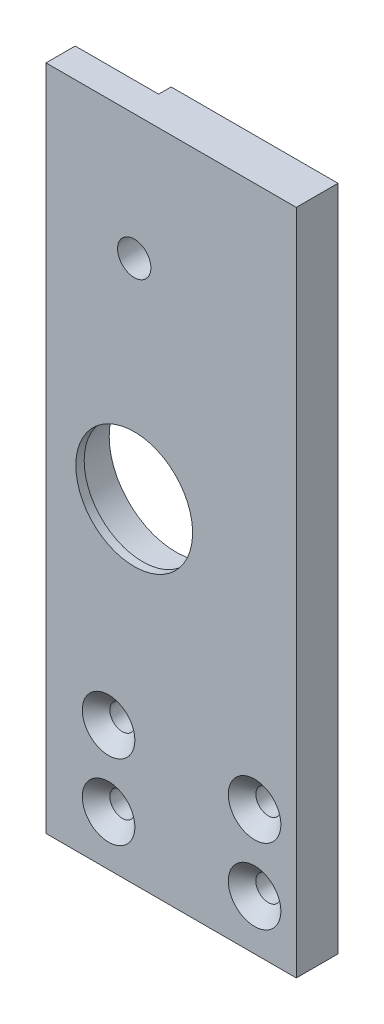
from build123d import *

# Parameters (mm, degrees)
SKIZZE1_W                        = 65
SKIZZE1_H                        = 160
AUFSATZ_LINEAR_AUSTRAGEN1_DEPTH  = 10
SKIZZE2_R                        = 16
SCHNITT_LINEAR_AUSTRAGEN1_DEPTH  = 8
SKIZZE3_W                        = 20
SKIZZE3_H                        = 3
SCHNITT_LINEAR_AUSTRAGEN2_DEPTH  = 15
SKIZZE4_R                        = 4
SCHNITT_LINEAR_AUSTRAGEN3_DEPTH  = 20
SKIZZE6_R                        = 14
SCHNITT_LINEAR_AUSTRAGEN4_DEPTH  = 20
SKIZZE7_R                        = 1.62
SCHNITT_LINEAR_AUSTRAGEN5_DEPTH  = 5
SKIZZE8_R                        = 1.62
SCHNITT_LINEAR_AUSTRAGEN6_DEPTH  = 5
SKIZZE9_R                        = 3
SCHNITT_LINEAR_AUSTRAGEN7_DEPTH  = 32
FASE1_SIZE                       = 3.3
SKIZZE10_R                       = 3
SCHNITT_LINEAR_AUSTRAGEN8_DEPTH  = 32
FASE2_SIZE                       = 3.3
SKIZZE11_R                       = 3
SCHNITT_LINEAR_AUSTRAGEN9_DEPTH  = 32
FASE3_SIZE                       = 3.3
SKIZZE12_R                       = 3
SCHNITT_LINEAR_AUSTRAGEN10_DEPTH = 25
FASE4_SIZE                       = 3.3
SKIZZE13_W                       = 10
SKIZZE13_H                       = 160
SCHNITT_LINEAR_AUSTRAGEN11_DEPTH = 5


with BuildPart() as part:
    # Skizze1 → Aufsatz-Linear austragen1 (new body)
    with BuildSketch(Plane.XY):
        with Locations((32.5, 80)):
            Rectangle(SKIZZE1_W, SKIZZE1_H)
    extrude(amount=AUFSATZ_LINEAR_AUSTRAGEN1_DEPTH)

    # Skizze2 → Schnitt-Linear austragen1 (cut)
    with BuildSketch(Plane(origin=(0, 0, 0), x_dir=(-1, 0, 0), z_dir=(0, 0, -1))):
        with Locations((-21.15, 80)):
            Circle(SKIZZE2_R)
    extrude(amount=-SCHNITT_LINEAR_AUSTRAGEN1_DEPTH, mode=Mode.SUBTRACT)

    # Skizze3 → Schnitt-Linear austragen2 (cut)
    with BuildSketch(Plane(origin=(0, 160, 0), x_dir=(1, 0, 0), z_dir=(0, 1, 0))):
        with Locations((10, -1.5)):
            Rectangle(SKIZZE3_W, SKIZZE3_H)
    extrude(amount=-SCHNITT_LINEAR_AUSTRAGEN2_DEPTH, mode=Mode.SUBTRACT)

    # Skizze4 → Schnitt-Linear austragen3 (cut)
    with BuildSketch(Plane(origin=(0, 0, 0), x_dir=(-1, 0, 0), z_dir=(0, 0, -1))):
        with Locations((-21.15, 130)):
            Circle(SKIZZE4_R)
    extrude(amount=-SCHNITT_LINEAR_AUSTRAGEN3_DEPTH, mode=Mode.SUBTRACT)

    # Skizze6 → Schnitt-Linear austragen4 (cut)
    with BuildSketch(Plane(origin=(0, 0, 8), x_dir=(-1, 0, 0), z_dir=(0, 0, -1))):
        with Locations((-21.15, 80)):
            Circle(SKIZZE6_R)
    extrude(amount=-SCHNITT_LINEAR_AUSTRAGEN4_DEPTH, mode=Mode.SUBTRACT)

    # Skizze7 → Schnitt-Linear austragen5 (cut)
    with BuildSketch(Plane(origin=(0, 0, 3), x_dir=(-1, 0, 0), z_dir=(0, 0, -1))):
        with Locations((-5, 151)):
            Circle(SKIZZE7_R)
    extrude(amount=-SCHNITT_LINEAR_AUSTRAGEN5_DEPTH, mode=Mode.SUBTRACT)

    # Skizze8 → Schnitt-Linear austragen6 (cut)
    with BuildSketch(Plane(origin=(0, 0, 3), x_dir=(-1, 0, 0), z_dir=(0, 0, -1))):
        with Locations((-15, 151)):
            Circle(SKIZZE8_R)
    extrude(amount=-SCHNITT_LINEAR_AUSTRAGEN6_DEPTH, mode=Mode.SUBTRACT)

    # Skizze9 → Schnitt-Linear austragen7 (cut)
    with BuildSketch(Plane.XY.offset(10)):
        with Locations((15, 12)):
            Circle(SKIZZE9_R)
    extrude(amount=-SCHNITT_LINEAR_AUSTRAGEN7_DEPTH, mode=Mode.SUBTRACT)

    # Fase1
    fase1_edges = [part.edges().sort_by_distance(p)[0] for p in [
        (12, 12, 10),
    ]]
    chamfer(fase1_edges, length=FASE1_SIZE)

    # Skizze10 → Schnitt-Linear austragen8 (cut)
    with BuildSketch(Plane.XY.offset(10)):
        with Locations((50, 12)):
            Circle(SKIZZE10_R)
    extrude(amount=-SCHNITT_LINEAR_AUSTRAGEN8_DEPTH, mode=Mode.SUBTRACT)

    # Fase2
    fase2_edges = [part.edges().sort_by_distance(p)[0] for p in [
        (47, 12, 10),
    ]]
    chamfer(fase2_edges, length=FASE2_SIZE)

    # Skizze11 → Schnitt-Linear austragen9 (cut)
    with BuildSketch(Plane.XY.offset(10)):
        with Locations((15, 30)):
            Circle(SKIZZE11_R)
    extrude(amount=-SCHNITT_LINEAR_AUSTRAGEN9_DEPTH, mode=Mode.SUBTRACT)

    # Fase3
    fase3_edges = [part.edges().sort_by_distance(p)[0] for p in [
        (12, 30, 10),
    ]]
    chamfer(fase3_edges, length=FASE3_SIZE)

    # Skizze12 → Schnitt-Linear austragen10 (cut)
    with BuildSketch(Plane.XY.offset(10)):
        with Locations((50, 30)):
            Circle(SKIZZE12_R)
    extrude(amount=-SCHNITT_LINEAR_AUSTRAGEN10_DEPTH, mode=Mode.SUBTRACT)

    # Fase4
    fase4_edges = [part.edges().sort_by_distance(p)[0] for p in [
        (47, 30, 10),
    ]]
    chamfer(fase4_edges, length=FASE4_SIZE)

    # Skizze13 → Schnitt-Linear austragen11 (cut)
    with BuildSketch(Plane(origin=(65, 0, 0), x_dir=(0, 0, -1), z_dir=(1, 0, 0))):
        with Locations((-5, 80)):
            Rectangle(SKIZZE13_W, SKIZZE13_H)
    extrude(amount=-SCHNITT_LINEAR_AUSTRAGEN11_DEPTH, mode=Mode.SUBTRACT)


solid = part.part
